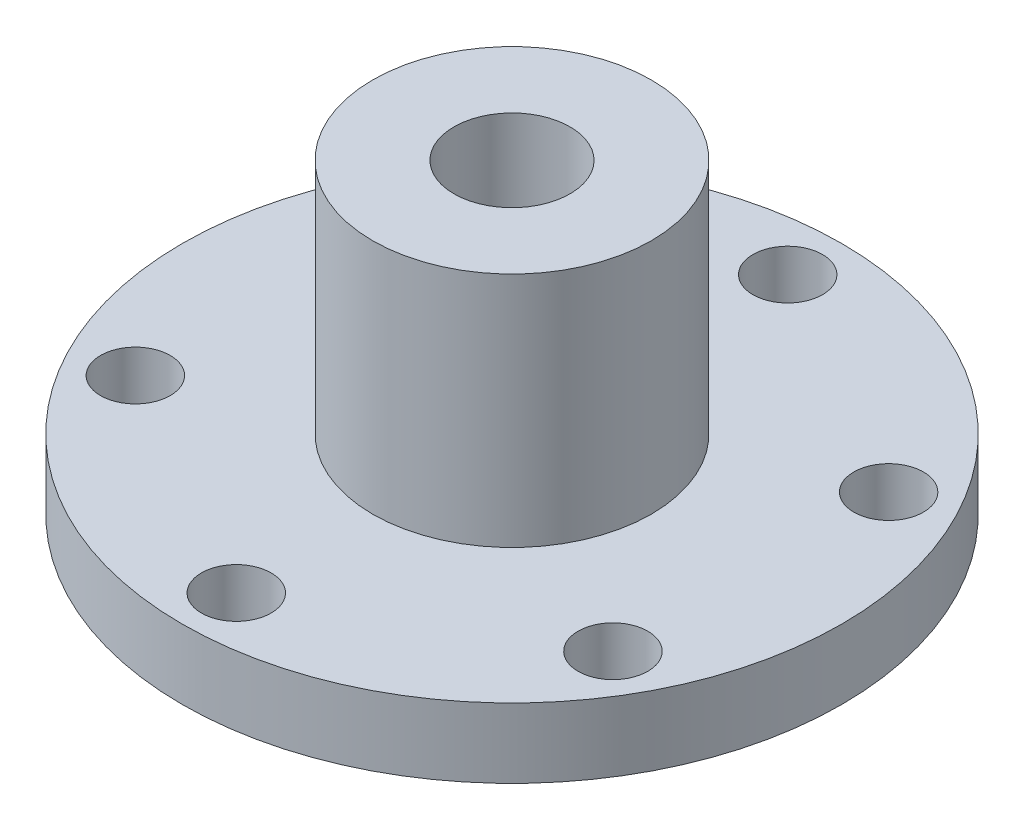
from build123d import *

# Parameters (mm, degrees)
SKETCH1_R           = 28.4
SKETCH1_R_2         = 5
SKETCH1_R_3         = 3
BOSS_EXTRUDE3_DEPTH = 6
SKETCH5_R           = 12
SKETCH5_R_2         = 5
BOSS_EXTRUDE4_DEPTH = 20.4


with BuildPart() as part:
    # Sketch1 → Boss-Extrude3 (new body)
    with BuildSketch(Plane(origin=(0, 0, 0), x_dir=(1, 0, 0), z_dir=(0, 1, 0))):
        Circle(SKETCH1_R)
        Circle(SKETCH1_R_2, mode=Mode.SUBTRACT)
        with Locations((0, 23.75)):
            Circle(SKETCH1_R_3, mode=Mode.SUBTRACT)
        with Locations((20.56810334, 11.875)):
            Circle(SKETCH1_R_3, mode=Mode.SUBTRACT)
        with Locations((20.56810334, -11.875)):
            Circle(SKETCH1_R_3, mode=Mode.SUBTRACT)
        with Locations((0, -23.75)):
            Circle(SKETCH1_R_3, mode=Mode.SUBTRACT)
        with Locations((-20.56810334, -11.875)):
            Circle(SKETCH1_R_3, mode=Mode.SUBTRACT)
        with Locations((-20.56810334, 11.875)):
            Circle(SKETCH1_R_3, mode=Mode.SUBTRACT)
    extrude(amount=BOSS_EXTRUDE3_DEPTH)

    # Sketch5 → Boss-Extrude4 (add)
    with BuildSketch(Plane(origin=(0, 6, 0), x_dir=(1, 0, 0), z_dir=(0, 1, 0))):
        Circle(SKETCH5_R)
        Circle(SKETCH5_R_2, mode=Mode.SUBTRACT)
    extrude(amount=BOSS_EXTRUDE4_DEPTH)


solid = part.part
